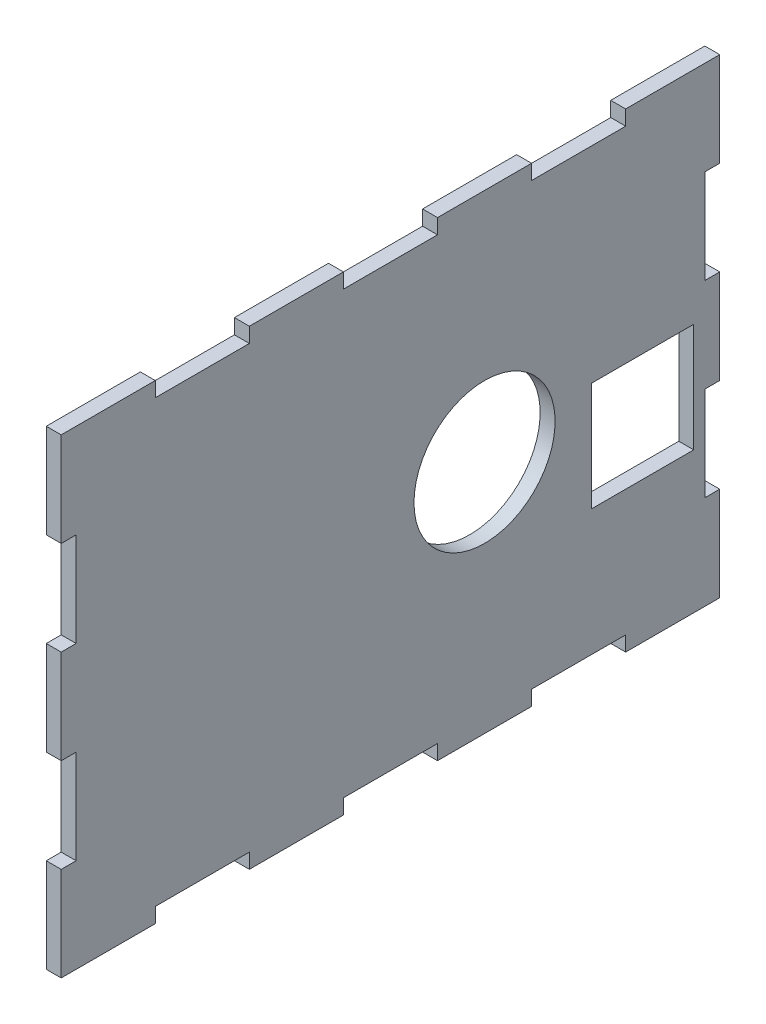
from build123d import *

# Parameters (mm, degrees)
SKETCH46_W           = 140
SKETCH46_H           = 99.999981374
SKETCH46_R           = 15
SKETCH46_W_2         = 21.745
SKETCH46_H_2         = 23.125
BOSS_EXTRUDE11_DEPTH = 3.175
SKETCH47_W           = 3.175
SKETCH47_H           = 20
SKETCH47_W_2         = 20
SKETCH47_H_2         = 3.175
CUT_EXTRUDE23_DEPTH  = 3.175


with BuildPart() as part:
    # Sketch46 → Boss-Extrude11 (new body)
    with BuildSketch(Plane.ZY):
        with Locations((668.101928689, 4.4643e-05)):
            Rectangle(SKETCH46_W, SKETCH46_H)
        with Locations((648.101928689, 4.4643e-05)):
            Circle(SKETCH46_R, mode=Mode.SUBTRACT)
        with Locations((614.504428689, -8.437455357)):
            Rectangle(SKETCH46_W_2, SKETCH46_H_2, mode=Mode.SUBTRACT)
    extrude(amount=BOSS_EXTRUDE11_DEPTH)

    # Sketch47 → Cut-Extrude23 (cut)
    with BuildSketch(Plane.ZY.offset(3.175)):
        with Locations((736.514428689, -19.99996467)):
            Rectangle(SKETCH47_W, SKETCH47_H)
        with Locations((736.514428689, 20.00003533)):
            Rectangle(SKETCH47_W, SKETCH47_H)
        with Locations((599.689428689, -19.99996467)):
            Rectangle(SKETCH47_W, SKETCH47_H)
        with Locations((599.689428689, 20.00003533)):
            Rectangle(SKETCH47_W, SKETCH47_H)
        with Locations((668.101928689, 48.41253533)):
            Rectangle(SKETCH47_W_2, SKETCH47_H_2)
        with Locations((708.101928689, 48.41253533)):
            Rectangle(SKETCH47_W_2, SKETCH47_H_2)
        with Locations((628.101928689, 48.41253533)):
            Rectangle(SKETCH47_W_2, SKETCH47_H_2)
        with Locations((668.101928689, -48.412446044)):
            Rectangle(SKETCH47_W_2, SKETCH47_H_2)
        with Locations((708.101928689, -48.412446044)):
            Rectangle(SKETCH47_W_2, SKETCH47_H_2)
        with Locations((628.101928689, -48.412446044)):
            Rectangle(SKETCH47_W_2, SKETCH47_H_2)
    extrude(amount=-CUT_EXTRUDE23_DEPTH, mode=Mode.SUBTRACT)


solid = part.part
